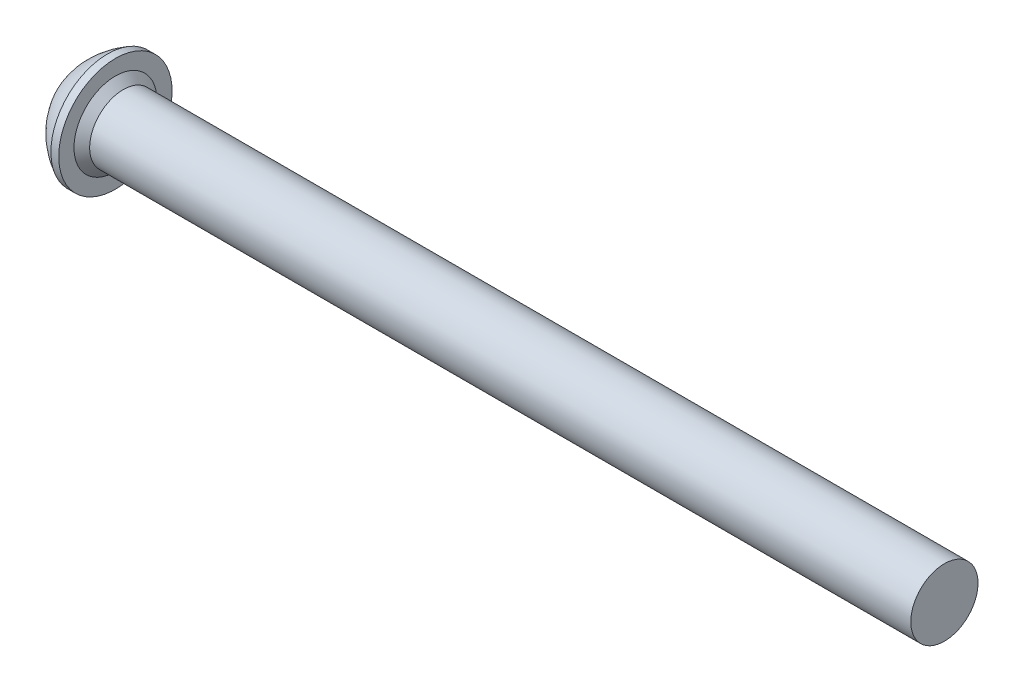
from build123d import *

# Parameters (mm, degrees)
CUT_EXTRUDE1_DEPTH = 1


with BuildPart() as part:
    # Sketch2 → Revolve1 (revolve)
    with BuildSketch(Plane.XY):
        with BuildLine():
            Line((0, 0), (0, 1.43))
            ThreePointArc((0, 1.43), (0.558633593, 2.055416372), (1.25, 2.53))
            Line((1.25, 2.53), (1.6, 2.53))
            Line((1.6, 2.53), (1.6, 1.85))
            Line((1.6, 1.85), (1.95, 1.5))
            Line((1.95, 1.5), (38.6, 1.5))
            Line((38.6, 1.5), (38.6, 0))
            Line((38.6, 0), (0, 0))
        make_face()
    revolve(axis=Axis((38.6, 0, 0), (-1, 0, 0)))

    # Sketch3 → Cut-Extrude1 (cut)
    with BuildSketch(Plane.ZY):
        Polygon((0, 1.154700538), (-1, 0.577350269), (-1, -0.577350269), (0, -1.154700538), (1, -0.577350269), (1, 0.577350269), align=None)
    extrude(amount=-CUT_EXTRUDE1_DEPTH, mode=Mode.SUBTRACT)


solid = part.part
